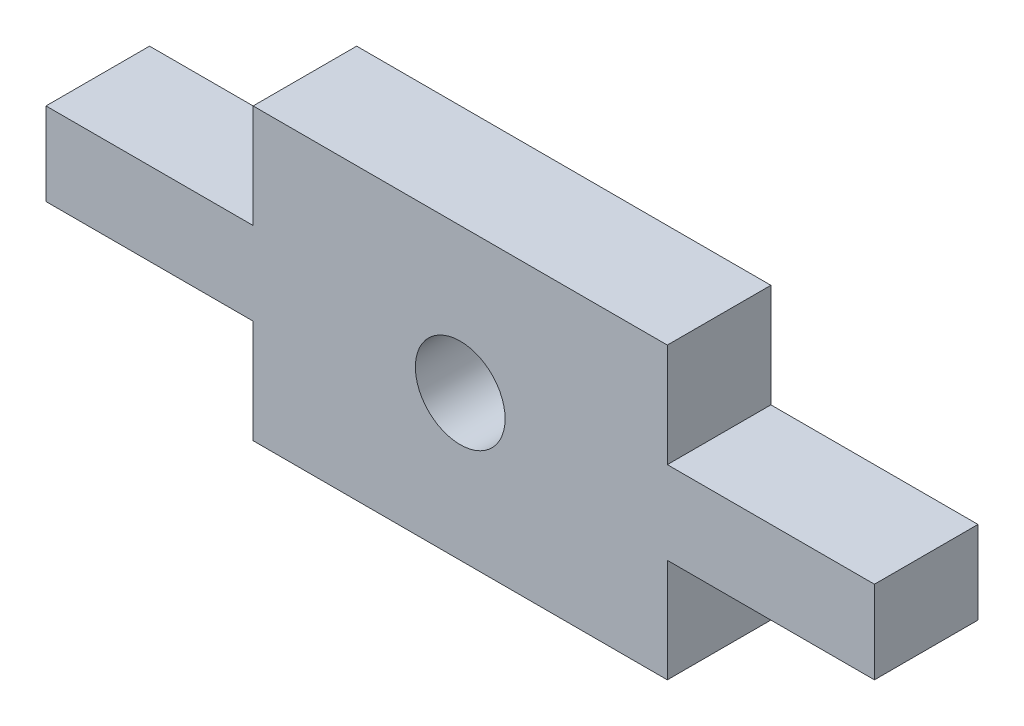
from build123d import *

# Parameters (mm, degrees)
MODEL_R             = 1.299950001
BOSS_EXTRUDE1_DEPTH = 3


with BuildPart() as part:
    # Model → Boss-Extrude1 (new body)
    with BuildSketch(Plane.XY):
        Polygon((47.999973659, 38.200066274), (53.99998683, 38.199995563), (54.00005754, 41.200037504), (66.00001317, 41.199966793), (66.000083881, 38.199924852), (72.000026341, 38.200066274), (72.000026341, 35.800004437), (66.00001317, 35.800075148), (66.00001317, 32.799962496), (54.000128251, 32.799962496), (53.99998683, 35.800075148), (47.999973659, 35.800004437), align=None)
        with Locations((60.000070711, 36.999964645)):
            Circle(MODEL_R, mode=Mode.SUBTRACT)
    extrude(amount=BOSS_EXTRUDE1_DEPTH)


solid = part.part
